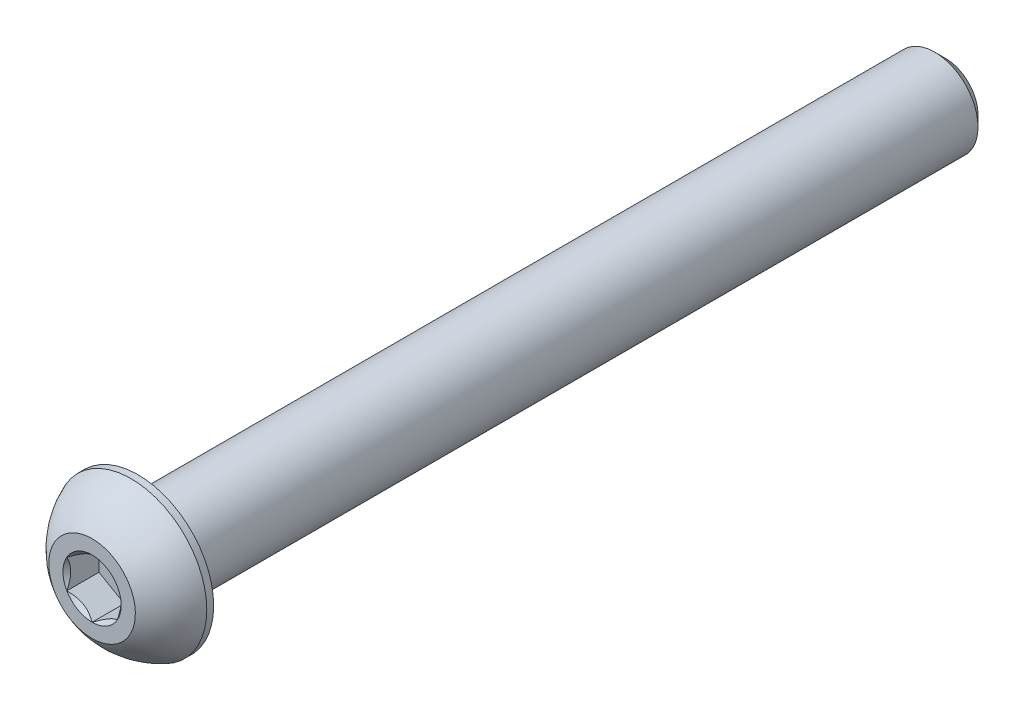
from build123d import *

# Parameters (mm, degrees)
SKETCH1_W          = 88.9
SKETCH1_H          = 4.7625
CHAMFER1_SIZE      = 1.190625
CUT_EXTRUDE2_DEPTH = 3.53822


with BuildPart() as part:
    # Sketch1 → Revolve1 (revolve)
    with BuildSketch(Plane(origin=(0, 0, 0), x_dir=(0, 0, -1), z_dir=(1, 0, 0))):
        with Locations((49.5046, 2.38125)):
            Rectangle(SKETCH1_W, SKETCH1_H)
    revolve(axis=Axis((0, 0, -93.9546), (0, 0, 1)))

    # Chamfer1
    chamfer1_edges = [part.edges().sort_by_distance(p)[0] for p in [
        (0, -4.7625, -93.9546),
    ]]
    chamfer(chamfer1_edges, length=CHAMFER1_SIZE)

    # Sketch7 → Revolve2 (revolve)
    with BuildSketch(Plane(origin=(0, 0, 0), x_dir=(0, 0, -1), z_dir=(1, 0, 0))):
        with BuildLine():
            Line((4.29641, 8.3312), (5.0546, 8.3312))
            Line((5.0546, 8.3312), (5.0546, 0))
            Line((5.0546, 0), (0, 0))
            Line((0, 0), (0, 4.7625))
            ThreePointArc((0, 4.7625), (1.862939611, 6.890285164), (4.29641, 8.3312))
        make_face()
    revolve(axis=Axis((0, 0, 0), (0, 0, -1)))

    # Sketch5 → Cut-Extrude2 (cut)
    with BuildSketch(Plane.XY):
        Polygon((2.778125, -1.603951217), (2.778125, 1.603951217), (0, 3.207902433), (-2.778125, 1.603951217), (-2.778125, -1.603951217), (0, -3.207902433), align=None)
    extrude(amount=-CUT_EXTRUDE2_DEPTH, mode=Mode.SUBTRACT)

    # Cut-Extrude3 cone 1 section (through the dimple's axis) → Cut-Extrude3 (revolve, cut)
    with BuildSketch(Plane(origin=(0, 0, 0), x_dir=(0, -1, 0), z_dir=(1, 0, 0))):
        Polygon((0, 0), (3.207902433, 0), (0, 3.207902433), align=None)
    revolve(axis=Axis((0, 0, 0), (0, 0, -1)), mode=Mode.SUBTRACT)


solid = part.part
